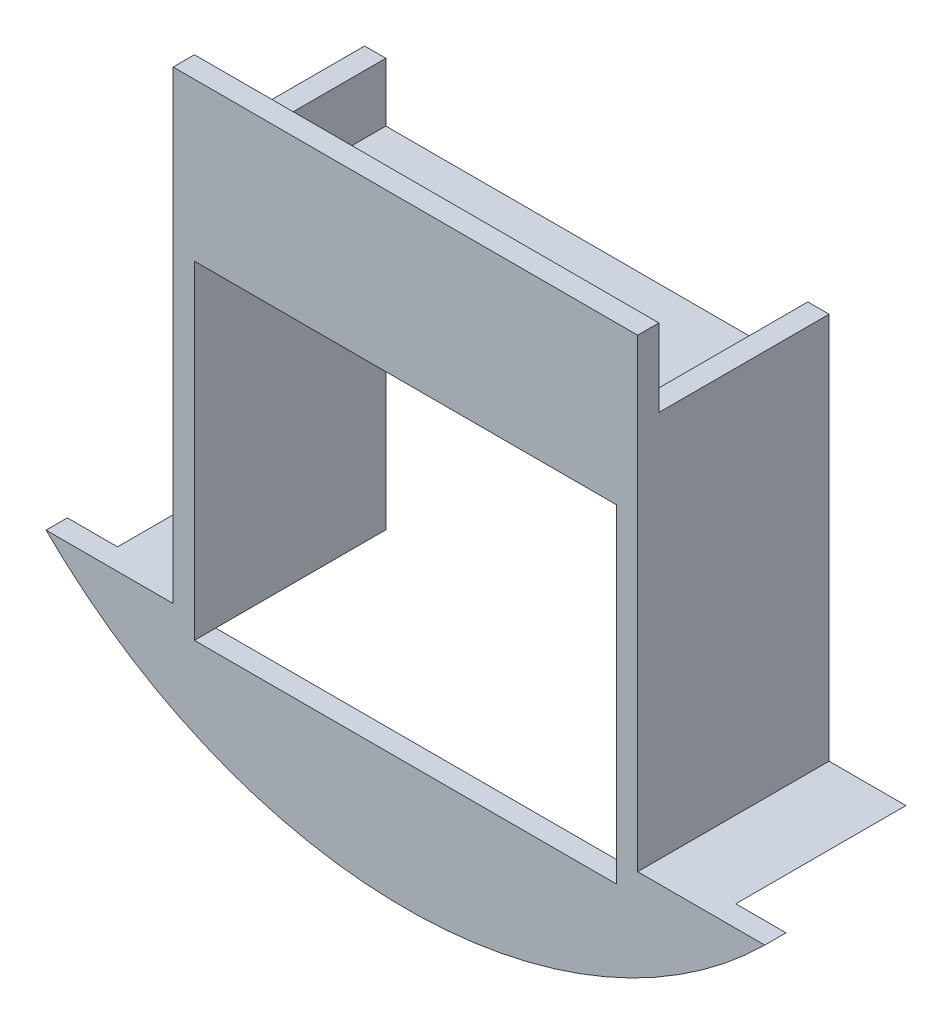
from build123d import *

# Parameters (mm, degrees)
BOSS_EXTRUDE2_DEPTH = 25.4
BOSS_EXTRUDE4_DEPTH = 25.4
SKETCH5_W           = 62.992
SKETCH5_H           = 49.022
BOSS_EXTRUDE5_DEPTH = 3.175


with BuildPart() as part:
    # Sketch2 → Boss-Extrude2 (new body)
    with BuildSketch(Plane.XY):
        Polygon((-34.671, -49.022), (-31.496, -49.022), (-31.496, 0), (31.496, 0), (31.496, -49.022), (34.671, -49.022), (34.671, 11.938), (31.496, 11.938), (31.496, 3.175), (-31.496, 3.175), (-31.496, 11.938), (-34.671, 11.938), align=None)
    extrude(amount=BOSS_EXTRUDE2_DEPTH)

    # Sketch4 → Boss-Extrude4 (add)
    with BuildSketch(Plane.XY.offset(25.4)):
        with BuildLine():
            Line((-34.671, -49.022), (-42.1386, -49.022))
            ThreePointArc((-42.1386, -49.022), (-44.170473584, -47.470511893), (-46.145273507, -45.847))
            Line((-46.145273507, -45.847), (-34.671, -45.847))
            Line((-34.671, -45.847), (-34.671, -49.022))
        make_face()
        with BuildLine():
            Line((34.671, -45.847), (34.671, -49.022))
            Line((34.671, -49.022), (42.1386, -49.022))
            ThreePointArc((42.1386, -49.022), (44.170473584, -47.470511893), (46.145273507, -45.847))
            Line((46.145273507, -45.847), (34.671, -45.847))
        make_face()
    extrude(amount=-BOSS_EXTRUDE4_DEPTH)

    # Sketch5 → Boss-Extrude5 (add)
    with BuildSketch(Plane.XY.offset(25.4)):
        with BuildLine():
            Line((-34.671, -45.847), (-34.671, 23.510170408))
            Line((-34.671, 23.510170408), (34.671, 23.510170408))
            Line((34.671, 23.510170408), (34.671, -45.847))
            Line((34.671, -45.847), (53.64486804, -45.847))
            ThreePointArc((53.64486804, -45.847), (0, -67.929829592), (-53.64486804, -45.847))
            Line((-53.64486804, -45.847), (-34.671, -45.847))
        make_face()
        with Locations((0, -24.511)):
            Rectangle(SKETCH5_W, SKETCH5_H, mode=Mode.SUBTRACT)
    extrude(amount=BOSS_EXTRUDE5_DEPTH)


solid = part.part
